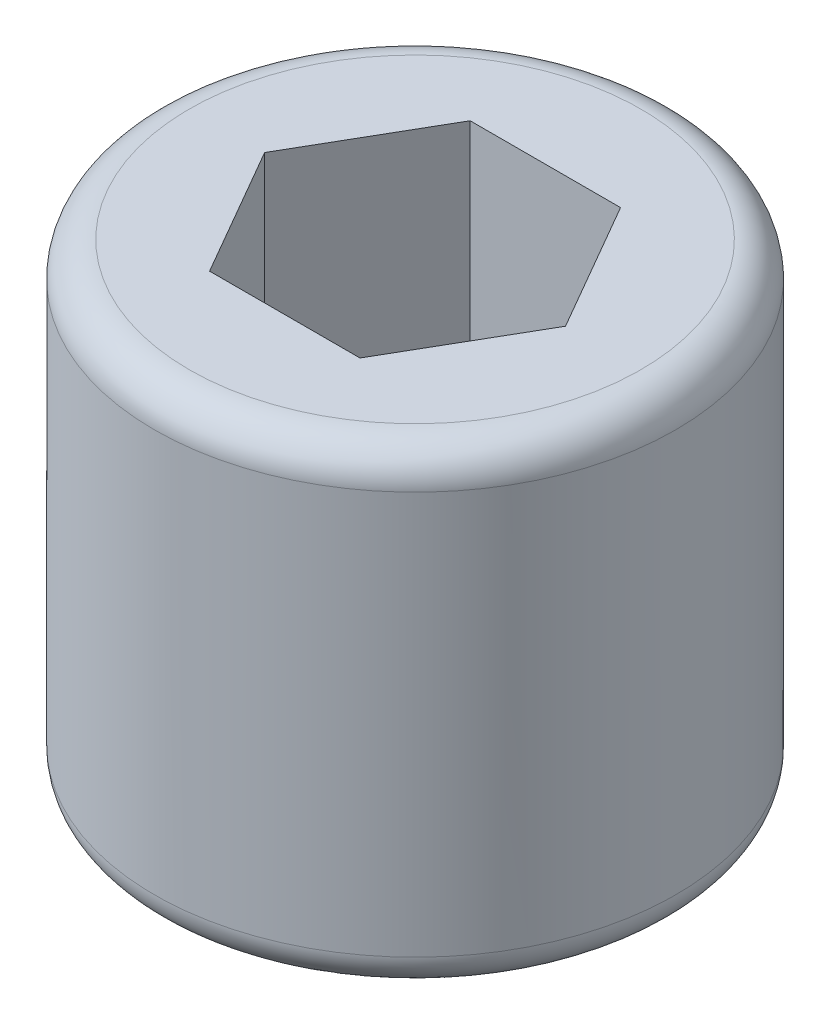
from build123d import *

# Parameters (mm, degrees)
SKETCH_1_R            = 1.5
EXTRUDE_254_DEPTH     = 3
CUT_EXTRUDE_384_DEPTH = 1.2
FILLET_1_R            = 0.2


with BuildPart() as part:
    # 草图1 → Extrude 254 (new body)
    with BuildSketch(Plane(origin=(0, 0, 0), x_dir=(1, 0, 0), z_dir=(0, 1, 0))):
        Circle(SKETCH_1_R)
    extrude(amount=EXTRUDE_254_DEPTH)

    # 草图2 → Cut-Extrude 384 (cut)
    with BuildSketch(Plane(origin=(0, 3, 0), x_dir=(1, 0, 0), z_dir=(0, 1, 0))):
        Polygon((0.866025404, 0), (0.433012702, 0.75), (-0.433012702, 0.75), (-0.866025404, 0), (-0.433012702, -0.75), (0.433012702, -0.75), align=None)
    extrude(amount=-CUT_EXTRUDE_384_DEPTH, mode=Mode.SUBTRACT)

    # 草图3 → 切除-旋转4 (revolve, cut)
    with BuildSketch(Plane.XY):
        Polygon((0.866025404, 0), (1.5, 0.366025404), (1.5, 0), align=None)
    revolve(axis=Axis((0, 3, 0), (0, -1, 0)), mode=Mode.SUBTRACT)

    # 圆角1
    fillet_1_edges = [part.edges().sort_by_distance(p)[0] for p in [
        (-1.5, 0.366025404, 0),
        (-1.5, 3, 0),
    ]]
    fillet(fillet_1_edges, radius=FILLET_1_R)


solid = part.part
